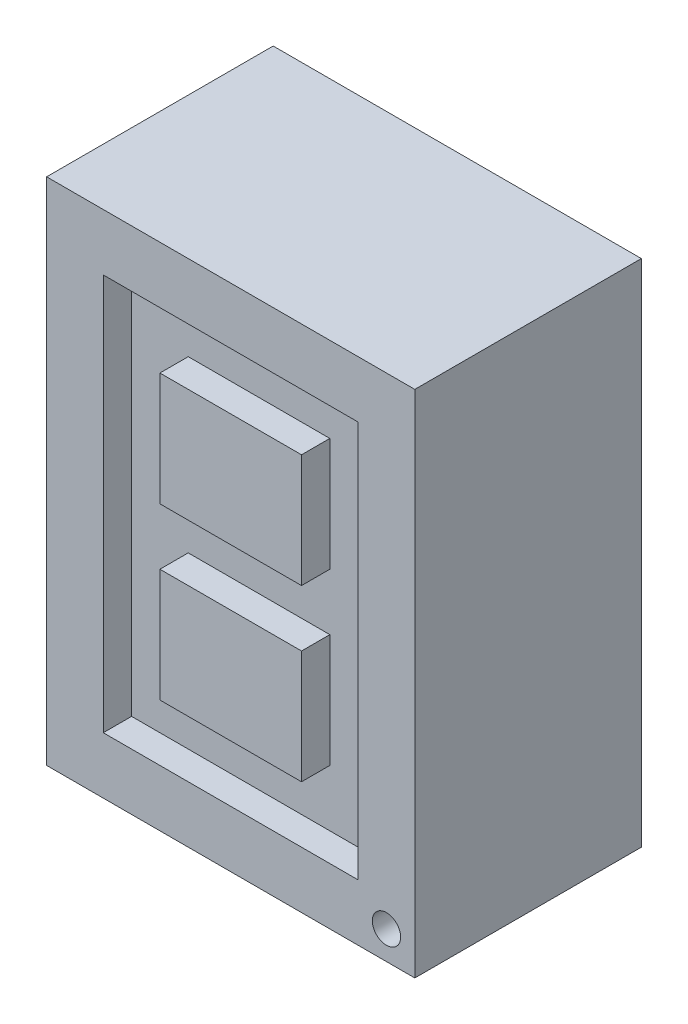
from build123d import *

# Parameters (mm, degrees)
ESQUISSE1_W             = 13
ESQUISSE1_H             = 18
BOSS_EXTRU_1_DEPTH      = 8
ESQUISSE2_R             = 0.5
ESQUISSE2_W             = 9
ESQUISSE2_H             = 14
ESQUISSE2_W_2           = 5
ESQUISSE2_H_2           = 4
ENL_V_MAT_EXTRU_1_DEPTH = 1


with BuildPart() as part:
    # Esquisse1 → Boss.-Extru.1 (new body)
    with BuildSketch(Plane.XY):
        with Locations((6.5, 9)):
            Rectangle(ESQUISSE1_W, ESQUISSE1_H)
    extrude(amount=BOSS_EXTRU_1_DEPTH)

    # Esquisse2 → Enlèv. mat.-Extru.1 (cut)
    with BuildSketch(Plane.XY.offset(8)):
        with Locations((12, 1)):
            Circle(ESQUISSE2_R)
        with Locations((6.5, 9)):
            Rectangle(ESQUISSE2_W, ESQUISSE2_H)
        with Locations((6.5, 12)):
            Rectangle(ESQUISSE2_W_2, ESQUISSE2_H_2, mode=Mode.SUBTRACT)
        with Locations((6.5, 6)):
            Rectangle(ESQUISSE2_W_2, ESQUISSE2_H_2, mode=Mode.SUBTRACT)
    extrude(amount=-ENL_V_MAT_EXTRU_1_DEPTH, mode=Mode.SUBTRACT)


solid = part.part
